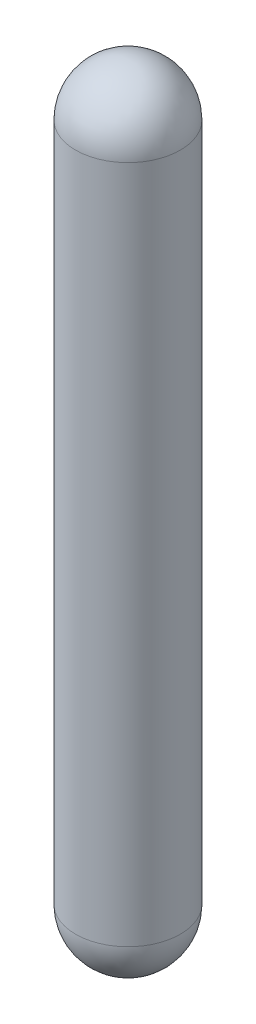
from build123d import *


with BuildPart() as part:
    # Sketch1 (on Front Plane) → Revolve1 (revolve)
    with BuildSketch(Plane.XY):
        with BuildLine():
            Line((-114.7826, 1729.74), (-114.7826, 0))
            ThreePointArc((-114.7826, 0), (-82.278429791, -80.033150968), (-3.175, -114.73867978))
            Line((-3.175, -114.73867978), (-3.175, -158.598723718))
            Line((-3.175, -158.598723718), (-6.35, -158.598723718))
            Line((-6.35, -158.598723718), (-6.35, -129.867447849))
            ThreePointArc((-6.35, -129.867447849), (-94.158164863, -89.666696718), (-130.0226, 0))
            Line((-130.0226, 0), (-130.0226, 1729.74))
            ThreePointArc((-130.0226, 1729.74), (-91.939862168, 1821.679862168), (0, 1859.7626))
            Line((0, 1859.7626), (0, 1844.5226))
            ThreePointArc((0, 1844.5226), (-81.163554822, 1810.903554822), (-114.7826, 1729.74))
        make_face()
    revolve(axis=Axis((0, 50.358015581, 0), (0, -1, 0)))


with BuildPart() as body_2:
    # Sketch1_4 → Revolve2 (revolve)
    with BuildSketch(Plane.XY):
        with BuildLine():
            ThreePointArc((-130.0226, 1729.74), (-91.939862168, 1821.679862168), (0, 1859.7626))
            Line((0, 1859.7626), (0, 1863.09))
            ThreePointArc((0, 1863.09), (-94.292689271, 1824.032689271), (-133.35, 1729.74))
            Line((-133.35, 1729.74), (-133.35, 0))
            ThreePointArc((-133.35, 0), (-96.511644375, -92.020242338), (-6.35, -133.198723718))
            Line((-6.35, -133.198723718), (-6.35, -129.867447849))
            ThreePointArc((-6.35, -129.867447849), (-94.158164863, -89.666696718), (-130.0226, 0))
            Line((-130.0226, 0), (-130.0226, 1729.74))
        make_face()
    revolve(axis=Axis((0, 50.358015581, 0), (0, -1, 0)))


solid = Compound([part.part, body_2.part])
